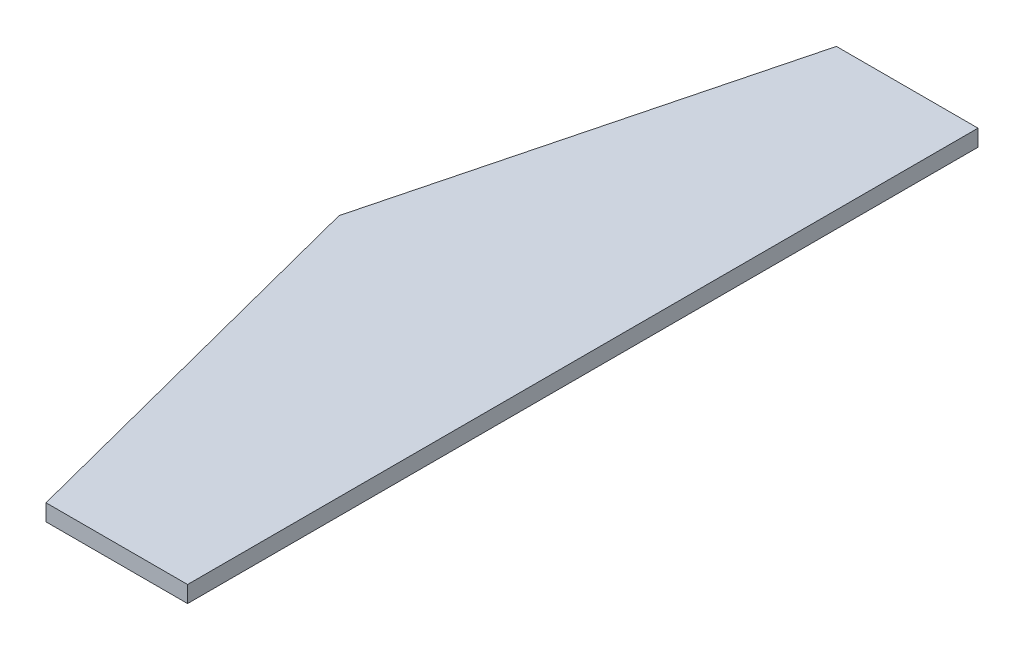
from build123d import *

# Parameters (mm, degrees)
BOSS_EXTRUDE1_DEPTH = 15


with BuildPart() as part:
    # Sketch1 → Boss-Extrude1 (new body)
    with BuildSketch(Plane(origin=(0, 0, 0), x_dir=(1, 0, 0), z_dir=(0, 1, 0))):
        Polygon((0, 430.296535077), (0, -286.403464923), (-128.371735874, -286.403464923), (-220.987286507, 71.946535077), (-128.371735874, 430.296535077), align=None)
    extrude(amount=BOSS_EXTRUDE1_DEPTH)


solid = part.part
